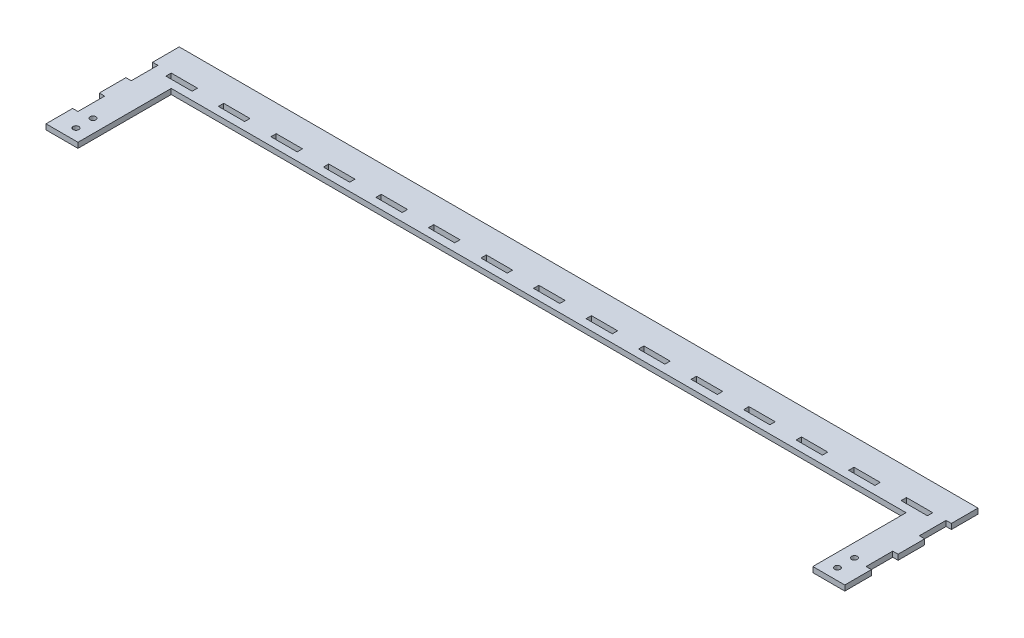
from build123d import *

# Parameters (mm, degrees)
SKETCH1_R           = 2.125
SKETCH1_W           = 19.725
SKETCH1_H           = 4
BOSS_EXTRUDE1_DEPTH = 4


with BuildPart() as part:
    # Sketch1 → Boss-Extrude1 (new body)
    with BuildSketch(Plane(origin=(0, 0, 0), x_dir=(1, 0, 0), z_dir=(0, 1, 0))):
        Polygon((299.8, 24), (299.8, 4), (295.8, 4), (295.8, -16), (299.8, -16), (299.8, -36), (295.8, -36), (295.8, -56), (299.8, -56), (299.8, -76), (275.8, -76), (275.8, -6), (-275.8, -6), (-275.8, -76), (-299.8, -76), (-299.8, -56), (-295.8, -56), (-295.8, -36), (-299.8, -36), (-299.8, -16), (-295.8, -16), (-295.8, 4), (-299.8, 4), (-299.8, 24), align=None)
        with Locations((285.8, -67.5)):
            Circle(SKETCH1_R, mode=Mode.SUBTRACT)
        with Locations((285.8, -54.75)):
            Circle(SKETCH1_R, mode=Mode.SUBTRACT)
        with Locations((-285.8, -54.75)):
            Circle(SKETCH1_R, mode=Mode.SUBTRACT)
        with Locations((-285.8, -67.5)):
            Circle(SKETCH1_R, mode=Mode.SUBTRACT)
        with Locations((0, 2)):
            Rectangle(SKETCH1_W, SKETCH1_H, mode=Mode.SUBTRACT)
        with Locations((39.45, 2)):
            Rectangle(SKETCH1_W, SKETCH1_H, mode=Mode.SUBTRACT)
        with Locations((78.87, 2)):
            Rectangle(SKETCH1_W, SKETCH1_H, mode=Mode.SUBTRACT)
        with Locations((118.29, 2)):
            Rectangle(SKETCH1_W, SKETCH1_H, mode=Mode.SUBTRACT)
        with Locations((157.71, 2)):
            Rectangle(SKETCH1_W, SKETCH1_H, mode=Mode.SUBTRACT)
        with Locations((197.13, 2)):
            Rectangle(SKETCH1_W, SKETCH1_H, mode=Mode.SUBTRACT)
        with Locations((236.55, 2)):
            Rectangle(SKETCH1_W, SKETCH1_H, mode=Mode.SUBTRACT)
        with Locations((275.97, 2)):
            Rectangle(SKETCH1_W, SKETCH1_H, mode=Mode.SUBTRACT)
        with Locations((-275.97, 2)):
            Rectangle(SKETCH1_W, SKETCH1_H, mode=Mode.SUBTRACT)
        with Locations((-236.55, 2)):
            Rectangle(SKETCH1_W, SKETCH1_H, mode=Mode.SUBTRACT)
        with Locations((-197.13, 2)):
            Rectangle(SKETCH1_W, SKETCH1_H, mode=Mode.SUBTRACT)
        with Locations((-157.71, 2)):
            Rectangle(SKETCH1_W, SKETCH1_H, mode=Mode.SUBTRACT)
        with Locations((-118.29, 2)):
            Rectangle(SKETCH1_W, SKETCH1_H, mode=Mode.SUBTRACT)
        with Locations((-78.87, 2)):
            Rectangle(SKETCH1_W, SKETCH1_H, mode=Mode.SUBTRACT)
        with Locations((-39.45, 2)):
            Rectangle(SKETCH1_W, SKETCH1_H, mode=Mode.SUBTRACT)
    extrude(amount=BOSS_EXTRUDE1_DEPTH)


solid = part.part
